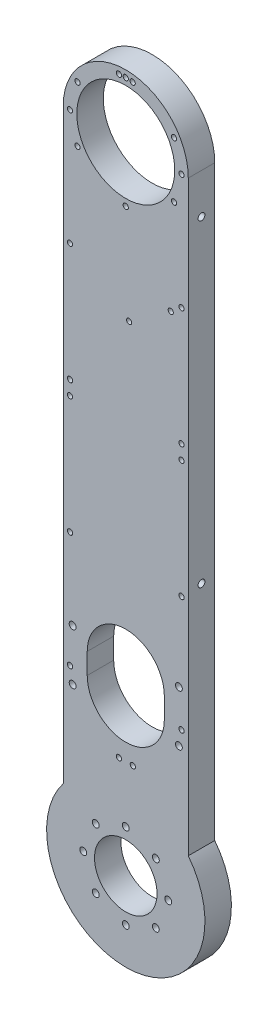
from build123d import *

# Parameters (mm, degrees)
BOSS_EXTRUDE1_DEPTH              = 12.7
CUT_EXTRUDE1_DEPTH               = 13.7
HOLE1_D                          = 30
HOLE1_DEPTH                      = 12.7
HOLE2_D                          = 47
HOLE2_DEPTH                      = 12.7
F_39_0_0995_DIAMETER_HOLE1_D     = 2.5273
F_39_0_0995_DIAMETER_HOLE1_DEPTH = 12.7
F_4_CLEARANCE_HOLE1_D            = 3.3
F_4_CLEARANCE_HOLE1_DEPTH        = 12.7
F_2_CLEARANCE_HOLE1_D            = 2.499999999
F_2_CLEARANCE_HOLE1_DEPTH        = 12.7
F_4_CLEARANCE_HOLE2_D            = 3.3
F_4_CLEARANCE_HOLE2_DEPTH        = 10


with BuildPart() as part:
    # Sketch1 → Boss-Extrude1 (new body)
    with BuildSketch(Plane.XY.offset(12.7)):
        with BuildLine():
            Line((-30, 305), (-30, 23.323807579))
            ThreePointArc((-30, 23.323807579), (0, -38), (30, 23.323807579))
            Line((30, 23.323807579), (30, 305))
            ThreePointArc((30, 305), (0, 335), (-30, 305))
        make_face()
    extrude(amount=-BOSS_EXTRUDE1_DEPTH)

    # Sketch2 → Cut-Extrude1 (cut, through all)
    with BuildSketch(Plane(origin=(0, 0, 0), x_dir=(-1, 0, 0), z_dir=(0, 0, -1))):
        with BuildLine():
            Line((18.5, 74.022471071), (18.5, 84.022471071))
            ThreePointArc((18.5, 84.022471071), (0, 102.522471071), (-18.5, 84.022471071))
            Line((-18.5, 84.022471071), (-18.5, 74.022471071))
            ThreePointArc((-18.5, 74.022471071), (0, 55.522471071), (18.5, 74.022471071))
        make_face()
    extrude(amount=-CUT_EXTRUDE1_DEPTH, mode=Mode.SUBTRACT)

    # Hole1
    with Locations(Plane.XY.offset(12.7)):
        with Locations((0, 0)):
            Hole(HOLE1_D / 2, depth=HOLE1_DEPTH)

    # Hole2
    with Locations(Plane.XY.offset(12.7)):
        with Locations((0, 305)):
            Hole(HOLE2_D / 2, depth=HOLE2_DEPTH)

    # #39 (0.0995) Diameter Hole1
    with Locations(Plane.XY.offset(12.7)):
        with Locations((-26.75, 74.022471071), (-26.75, 129.511235535), (-26.75, 186.111235535), (-26.750000001, 192.911235535), (-26.750000001, 249.511235535), (-26.750000001, 305), (-3.300000001, 331.545668196), (3.299999999, 331.545668196), (26.749999999, 305), (26.749999999, 249.511235535), (26.749999999, 192.911235535), (26.75, 186.111235535), (26.75, 129.511235535), (26.75, 74.022471071), (3.4, 47.489425637), (-3.3, 47.476802874), (-23.166179551, 318.375), (-23.166179551, 291.625), (0, 278.25), (23.166179551, 291.625), (23.166179551, 318.375), (0, 331.75)):
            Hole(F_39_0_0995_DIAMETER_HOLE1_D / 2, depth=F_39_0_0995_DIAMETER_HOLE1_DEPTH)

    # #4 Clearance Hole1
    with Locations(Plane(origin=(0, 0, 0), x_dir=(-1, 0, 0), z_dir=(0, 0, -1))):
        with Locations((-25.5016, 66.772471071), (-25.5016, 91.272471071), (14.424978336, 14.424978336), (20.4, 0), (14.424978336, -14.424978336), (0, -20.4), (-14.424978336, -14.424978336), (-20.4, 0), (-14.424978336, 14.424978336), (0, 20.4), (25.5016, 66.772471071), (25.5016, 91.272471071)):
            Hole(F_4_CLEARANCE_HOLE1_D / 2, depth=F_4_CLEARANCE_HOLE1_DEPTH)

    # #2 Clearance Hole1
    with Locations(Plane(origin=(0, 0, 0), x_dir=(-1, 0, 0), z_dir=(0, 0, -1))):
        with Locations((-1.619921459, 231.265288591), (-21.578861519, 245.43367635)):
            Hole(F_2_CLEARANCE_HOLE1_D / 2, depth=F_2_CLEARANCE_HOLE1_DEPTH)

    # #4 Clearance Hole2
    with Locations(Plane(origin=(30, 0, 0), x_dir=(0, 0, -1), z_dir=(1, 0, 0))):
        with Locations((-6.35, 285.723807579), (-6.35, 133.323807579)):
            Hole(F_4_CLEARANCE_HOLE2_D / 2, depth=F_4_CLEARANCE_HOLE2_DEPTH)


solid = part.part
